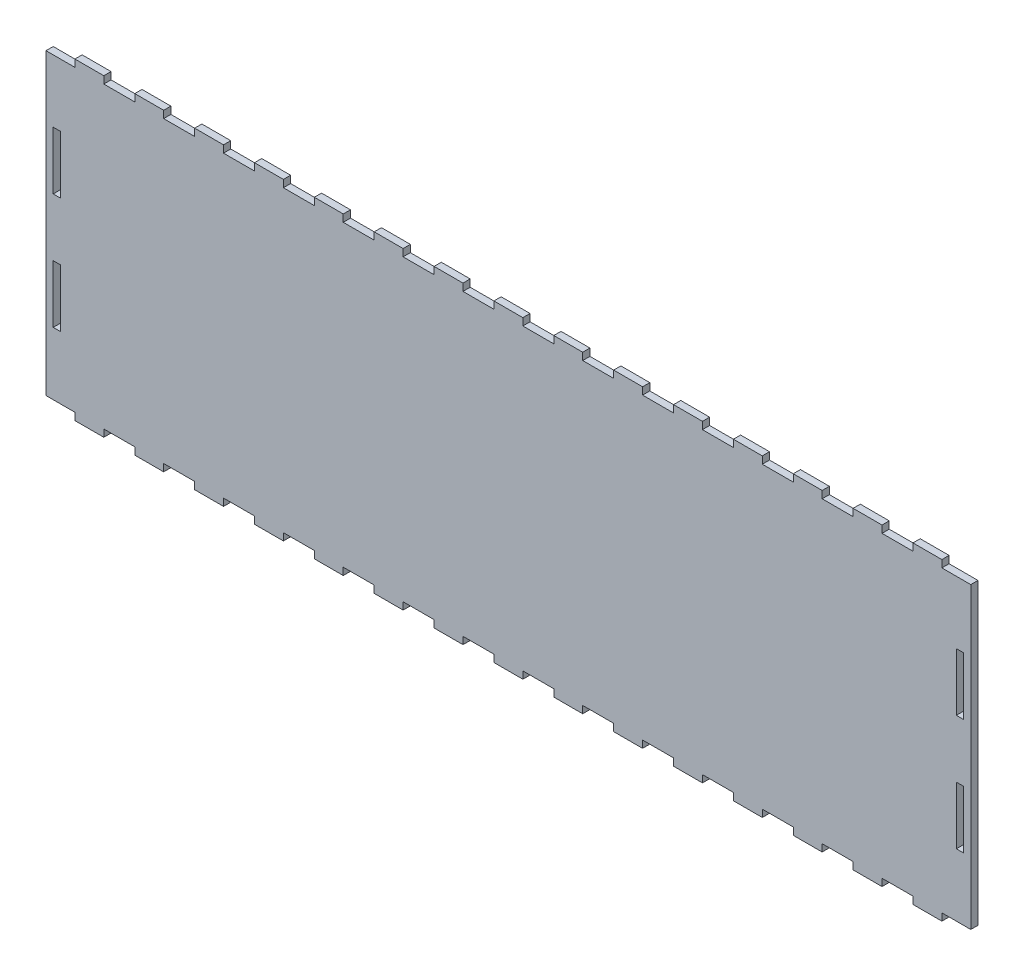
from build123d import *

# Parameters (mm, degrees)
SKETCH1_W           = 3.175
SKETCH1_H           = 25.4
BOSS_EXTRUDE1_DEPTH = 3.175


with BuildPart() as part:
    # Sketch1 → Boss-Extrude1 (new body)
    with BuildSketch(Plane.XY):
        Polygon((406.4, 0), (406.4, 131.2672), (393.7, 131.2672), (393.7, 134.4422), (381, 134.4422), (381, 131.2672), (367.392857143, 131.2672), (367.392857143, 134.4422), (354.692857143, 134.4422), (354.692857143, 131.2672), (341.085714286, 131.2672), (341.085714286, 134.4422), (328.385714286, 134.4422), (328.385714286, 131.2672), (314.778571429, 131.2672), (314.778571429, 134.4422), (302.078571429, 134.4422), (302.078571429, 131.2672), (288.471428571, 131.2672), (288.471428571, 134.4422), (275.771428571, 134.4422), (275.771428571, 131.2672), (262.164285714, 131.2672), (262.164285714, 134.4422), (249.464285714, 134.4422), (249.464285714, 131.2672), (235.857142857, 131.2672), (235.857142857, 134.4422), (223.157142857, 134.4422), (223.157142857, 131.2672), (209.55, 131.2672), (209.55, 134.4422), (196.85, 134.4422), (196.85, 131.2672), (183.242857143, 131.2672), (183.242857143, 134.4422), (170.542857143, 134.4422), (170.542857143, 131.2672), (156.935714286, 131.2672), (156.935714286, 134.4422), (144.235714286, 134.4422), (144.235714286, 131.2672), (130.628571429, 131.2672), (130.628571429, 134.4422), (117.928571429, 134.4422), (117.928571429, 131.2672), (104.321428571, 131.2672), (104.321428571, 134.4422), (91.621428571, 134.4422), (91.621428571, 131.2672), (78.014285714, 131.2672), (78.014285714, 134.4422), (65.314285714, 134.4422), (65.314285714, 131.2672), (51.707142857, 131.2672), (51.707142857, 134.4422), (39.007142857, 134.4422), (39.007142857, 131.2672), (25.4, 131.2672), (25.4, 134.4422), (12.7, 134.4422), (12.7, 131.2672), (0, 131.2672), (0, 0), (12.7, 0), (12.7, -3.175), (25.4, -3.175), (25.4, 0), (39.007142857, 0), (39.007142857, -3.175), (51.707142857, -3.175), (51.707142857, 0), (65.314285714, 0), (65.314285714, -3.175), (78.014285714, -3.175), (78.014285714, 0), (91.621428571, 0), (91.621428571, -3.175), (104.321428571, -3.175), (104.321428571, 0), (117.928571429, 0), (117.928571429, -3.175), (130.628571429, -3.175), (130.628571429, 0), (144.235714286, 0), (144.235714286, -3.175), (156.935714286, -3.175), (156.935714286, 0), (170.542857143, 0), (170.542857143, -3.175), (183.242857143, -3.175), (183.242857143, 0), (196.85, 0), (196.85, -3.175), (209.55, -3.175), (209.55, 0), (223.157142857, 0), (223.157142857, -3.175), (235.857142857, -3.175), (235.857142857, 0), (249.464285714, 0), (249.464285714, -3.175), (262.164285714, -3.175), (262.164285714, 0), (275.771428571, 0), (275.771428571, -3.175), (288.471428571, -3.175), (288.471428571, 0), (302.078571429, 0), (302.078571429, -3.175), (314.778571429, -3.175), (314.778571429, 0), (328.385714286, 0), (328.385714286, -3.175), (341.085714286, -3.175), (341.085714286, 0), (354.692857143, 0), (354.692857143, -3.175), (367.392857143, -3.175), (367.392857143, 0), (381, 0), (381, -3.175), (393.7, -3.175), (393.7, 0), align=None)
        with Locations((4.7625, 91.0336)):
            Rectangle(SKETCH1_W, SKETCH1_H, mode=Mode.SUBTRACT)
        with Locations((4.7625, 40.2336)):
            Rectangle(SKETCH1_W, SKETCH1_H, mode=Mode.SUBTRACT)
        with Locations((401.6375, 91.0336)):
            Rectangle(SKETCH1_W, SKETCH1_H, mode=Mode.SUBTRACT)
        with Locations((401.6375, 40.2336)):
            Rectangle(SKETCH1_W, SKETCH1_H, mode=Mode.SUBTRACT)
    extrude(amount=BOSS_EXTRUDE1_DEPTH)


solid = part.part
